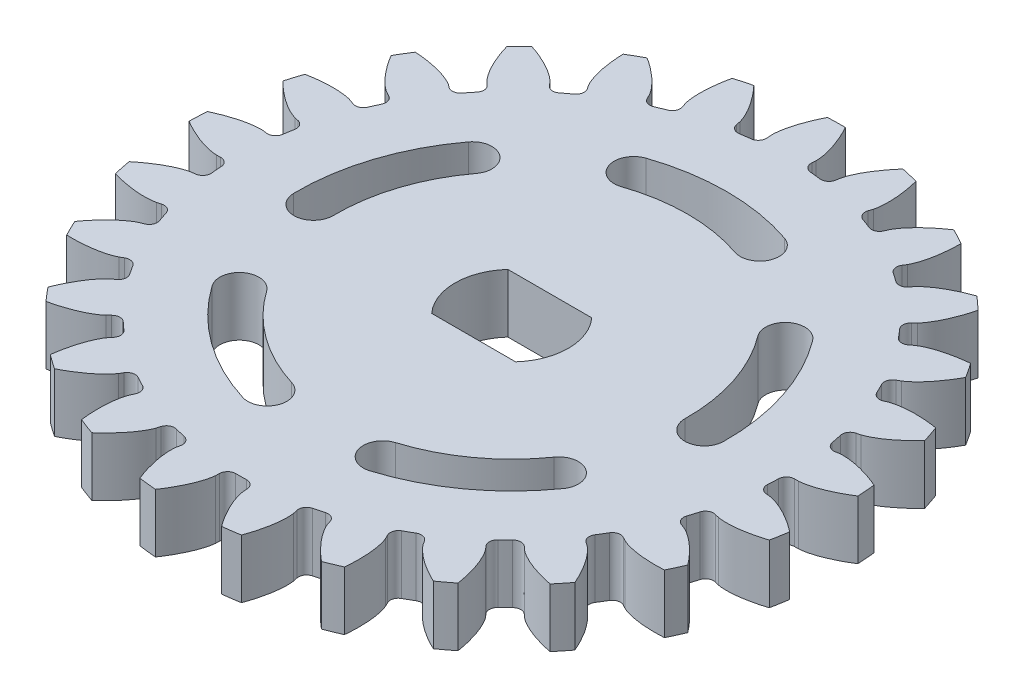
from build123d import *

# Parameters (mm, degrees)
SKETCH1_R                  = 16.875
BOSS_EXTRUDE1_DEPTH        = 3
CUT_EXTRUDE1_DEPTH         = 4
CIRPATTERN19_COUNT         = 25
CIRPATTERN19_COPY_1_DEPTH  = 4
CIRPATTERN19_COPY_2_DEPTH  = 4
CIRPATTERN19_COPY_3_DEPTH  = 4
CIRPATTERN19_COPY_4_DEPTH  = 4
CIRPATTERN19_COPY_5_DEPTH  = 4
CIRPATTERN19_COPY_6_DEPTH  = 4
CIRPATTERN19_COPY_7_DEPTH  = 4
CIRPATTERN19_COPY_8_DEPTH  = 4
CIRPATTERN19_COPY_9_DEPTH  = 4
CIRPATTERN19_COPY_10_DEPTH = 4
CIRPATTERN19_COPY_11_DEPTH = 4
CIRPATTERN19_COPY_12_DEPTH = 4
CIRPATTERN19_COPY_13_DEPTH = 4
CIRPATTERN19_COPY_14_DEPTH = 4
CIRPATTERN19_COPY_15_DEPTH = 4
CIRPATTERN19_COPY_16_DEPTH = 4
CIRPATTERN19_COPY_17_DEPTH = 4
CIRPATTERN19_COPY_18_DEPTH = 4
CIRPATTERN19_COPY_19_DEPTH = 4
CIRPATTERN19_COPY_20_DEPTH = 4
CIRPATTERN19_COPY_21_DEPTH = 4
CIRPATTERN19_COPY_22_DEPTH = 4
CIRPATTERN19_COPY_23_DEPTH = 4
CIRPATTERN19_COPY_24_DEPTH = 4
CUT_EXTRUDE2_DEPTH         = 4.0000049
CUT_EXTRUDE3_DEPTH         = 4.0000049
CIRPATTERN20_COUNT         = 5


with BuildPart() as part:
    # Sketch1 → Boss-Extrude1 (new body)
    with BuildSketch(Plane(origin=(0, 0, 0), x_dir=(1, 0, 0), z_dir=(0, 1, 0))):
        Circle(SKETCH1_R)
    extrude(amount=-BOSS_EXTRUDE1_DEPTH)

    # Sketch2 → Cut-Extrude1 (cut, through all)
    with BuildSketch(Plane(origin=(0, 0, 0), x_dir=(1, 0, 0), z_dir=(0, 1, 0))):
        with BuildLine():
            Line((14.473170221, 0), (14.6826972, 0))
            add(Edge.make_bspline(
                [(14.6826972, 0), (14.687716537, 7.2212e-05), (14.701790992, 0.000498376), (14.728380503, 0.00218708), (14.771710632, 0.006195704), (14.826812481, 0.013143385), (14.897864508, 0.024232683), (14.981306932, 0.040003826), (15.072684246, 0.060165733), (15.171694457, 0.085145599), (15.270071215, 0.112751457), (15.367794105, 0.14277984), (15.464743149, 0.174933677), (15.581665779, 0.216519036), (15.721125406, 0.270043417), (15.882938468, 0.337902676), (16.064963773, 0.421092777), (16.24872437, 0.512478794), (16.428052554, 0.607810489), (16.607375654, 0.710283683), (16.779548819, 0.813789215), (16.956297294, 0.927518774), (17.118396155, 1.035668484), (17.297531984, 1.163631233), (17.441387655, 1.268891216), (17.587819786, 1.383229542), (17.658763834, 1.439702537), (17.69488153, 1.468909522)],
                knots=[0, 0, 0, 0, 0, 0.005376749, 0.015083688, 0.02853182, 0.04661014, 0.064854849, 0.092110525, 0.119476176, 0.146842496, 0.174208854, 0.201574956, 0.228941013, 0.256307345, 0.307035032, 0.361767352, 0.416499661, 0.471231937, 0.525964282, 0.580696616, 0.635428982, 0.690161387, 0.744893688, 0.799626082, 0.854358408, 0.909090915, 0.909090915, 0.909090915, 0.909090915, 0.909090915], degree=4))
            Line((17.69488153, 1.468909522), (17.892777101, -0.858215161))
            Line((17.892777101, -0.858215161), (14.046351922, -0.673723934))
            ThreePointArc((14.046351922, -0.673723934), (14.052157943, -0.539224806), (14.056676114, -0.404676259))
            ThreePointArc((14.056676114, -0.404676259), (14.18281259, -0.117829659), (14.473170221, 0))
        make_face()
    cut_extrude1 = extrude(amount=-CUT_EXTRUDE1_DEPTH, mode=Mode.SUBTRACT)

    # Mirror2: Cut-Extrude1 across plane
    add(cut_extrude1.mirror(Plane(origin=(0, 0, 0), x_dir=(0.998851692, 0, 0.047909258), z_dir=(0.047909258, 0, -0.998851692))), mode=Mode.SUBTRACT)

    # CirPattern19: Cut-Extrude1 ×25 about axis
    cirpattern19_axis = Axis((0, 0, 0), (0, 1, 0))
    for i in range(1, CIRPATTERN19_COUNT):
        add(cut_extrude1.rotate(cirpattern19_axis, i * 360 / CIRPATTERN19_COUNT), mode=Mode.SUBTRACT)

    # CirPattern19 copy 1 sketch → CirPattern19 copy 1 (cut, through all)
    with BuildSketch(Plane(origin=(0, 0, 0), x_dir=(0.987938522, 0, -0.154846625), z_dir=(0, 1, 0))):
        with BuildLine():
            Line((14.473170221, 0), (14.6826972, 0))
            add(Edge.make_bspline(
                [(14.6826972, 0), (14.687716537, -7.2212e-05), (14.701790992, -0.000498376), (14.728380503, -0.00218708), (14.771710632, -0.006195704), (14.826812481, -0.013143385), (14.897864508, -0.024232683), (14.981306932, -0.040003826), (15.072684246, -0.060165733), (15.171694457, -0.085145599), (15.270071215, -0.112751457), (15.367794105, -0.14277984), (15.464743149, -0.174933677), (15.581665779, -0.216519036), (15.721125406, -0.270043417), (15.882938468, -0.337902676), (16.064963773, -0.421092777), (16.24872437, -0.512478794), (16.428052554, -0.607810489), (16.607375654, -0.710283683), (16.779548819, -0.813789215), (16.956297294, -0.927518774), (17.118396155, -1.035668484), (17.297531984, -1.163631233), (17.441387655, -1.268891216), (17.587819786, -1.383229542), (17.658763834, -1.439702537), (17.69488153, -1.468909522)],
                knots=[0, 0, 0, 0, 0, 0.005376749, 0.015083688, 0.02853182, 0.04661014, 0.064854849, 0.092110525, 0.119476176, 0.146842496, 0.174208854, 0.201574956, 0.228941013, 0.256307345, 0.307035032, 0.361767352, 0.416499661, 0.471231937, 0.525964282, 0.580696616, 0.635428982, 0.690161387, 0.744893688, 0.799626082, 0.854358408, 0.909090915, 0.909090915, 0.909090915, 0.909090915, 0.909090915], degree=4))
            Line((17.69488153, -1.468909522), (17.892777101, 0.858215161))
            Line((17.892777101, 0.858215161), (14.046351922, 0.673723934))
            ThreePointArc((14.046351922, 0.673723934), (14.052157943, 0.539224806), (14.056676114, 0.404676259))
            ThreePointArc((14.056676114, 0.404676259), (14.18281259, 0.117829659), (14.473170221, 0))
        make_face()
    extrude(amount=-CIRPATTERN19_COPY_1_DEPTH, mode=Mode.SUBTRACT)

    # CirPattern19 copy 2 sketch → CirPattern19 copy 2 (cut, through all)
    with BuildSketch(Plane(origin=(0, 0, 0), x_dir=(0.918391827, 0, -0.395672153), z_dir=(0, 1, 0))):
        with BuildLine():
            Line((14.473170221, 0), (14.6826972, 0))
            add(Edge.make_bspline(
                [(14.6826972, 0), (14.687716537, -7.2212e-05), (14.701790992, -0.000498376), (14.728380503, -0.00218708), (14.771710632, -0.006195704), (14.826812481, -0.013143385), (14.897864508, -0.024232683), (14.981306932, -0.040003826), (15.072684246, -0.060165733), (15.171694457, -0.085145599), (15.270071215, -0.112751457), (15.367794105, -0.14277984), (15.464743149, -0.174933677), (15.581665779, -0.216519036), (15.721125406, -0.270043417), (15.882938468, -0.337902676), (16.064963773, -0.421092777), (16.24872437, -0.512478794), (16.428052554, -0.607810489), (16.607375654, -0.710283683), (16.779548819, -0.813789215), (16.956297294, -0.927518774), (17.118396155, -1.035668484), (17.297531984, -1.163631233), (17.441387655, -1.268891216), (17.587819786, -1.383229542), (17.658763834, -1.439702537), (17.69488153, -1.468909522)],
                knots=[0, 0, 0, 0, 0, 0.005376749, 0.015083688, 0.02853182, 0.04661014, 0.064854849, 0.092110525, 0.119476176, 0.146842496, 0.174208854, 0.201574956, 0.228941013, 0.256307345, 0.307035032, 0.361767352, 0.416499661, 0.471231937, 0.525964282, 0.580696616, 0.635428982, 0.690161387, 0.744893688, 0.799626082, 0.854358408, 0.909090915, 0.909090915, 0.909090915, 0.909090915, 0.909090915], degree=4))
            Line((17.69488153, -1.468909522), (17.892777101, 0.858215161))
            Line((17.892777101, 0.858215161), (14.046351922, 0.673723934))
            ThreePointArc((14.046351922, 0.673723934), (14.052157943, 0.539224806), (14.056676114, 0.404676259))
            ThreePointArc((14.056676114, 0.404676259), (14.18281259, 0.117829659), (14.473170221, 0))
        make_face()
    extrude(amount=-CIRPATTERN19_COPY_2_DEPTH, mode=Mode.SUBTRACT)

    # CirPattern19 copy 3 sketch → CirPattern19 copy 3 (cut, through all)
    with BuildSketch(Plane(origin=(0, 0, 0), x_dir=(0.791139195, 0, -0.611636145), z_dir=(0, 1, 0))):
        with BuildLine():
            Line((14.473170221, 0), (14.6826972, 0))
            add(Edge.make_bspline(
                [(14.6826972, 0), (14.687716537, -7.2212e-05), (14.701790992, -0.000498376), (14.728380503, -0.00218708), (14.771710632, -0.006195704), (14.826812481, -0.013143385), (14.897864508, -0.024232683), (14.981306932, -0.040003826), (15.072684246, -0.060165733), (15.171694457, -0.085145599), (15.270071215, -0.112751457), (15.367794105, -0.14277984), (15.464743149, -0.174933677), (15.581665779, -0.216519036), (15.721125406, -0.270043417), (15.882938468, -0.337902676), (16.064963773, -0.421092777), (16.24872437, -0.512478794), (16.428052554, -0.607810489), (16.607375654, -0.710283683), (16.779548819, -0.813789215), (16.956297294, -0.927518774), (17.118396155, -1.035668484), (17.297531984, -1.163631233), (17.441387655, -1.268891216), (17.587819786, -1.383229542), (17.658763834, -1.439702537), (17.69488153, -1.468909522)],
                knots=[0, 0, 0, 0, 0, 0.005376749, 0.015083688, 0.02853182, 0.04661014, 0.064854849, 0.092110525, 0.119476176, 0.146842496, 0.174208854, 0.201574956, 0.228941013, 0.256307345, 0.307035032, 0.361767352, 0.416499661, 0.471231937, 0.525964282, 0.580696616, 0.635428982, 0.690161387, 0.744893688, 0.799626082, 0.854358408, 0.909090915, 0.909090915, 0.909090915, 0.909090915, 0.909090915], degree=4))
            Line((17.69488153, -1.468909522), (17.892777101, 0.858215161))
            Line((17.892777101, 0.858215161), (14.046351922, 0.673723934))
            ThreePointArc((14.046351922, 0.673723934), (14.052157943, 0.539224806), (14.056676114, 0.404676259))
            ThreePointArc((14.056676114, 0.404676259), (14.18281259, 0.117829659), (14.473170221, 0))
        make_face()
    extrude(amount=-CIRPATTERN19_COPY_3_DEPTH, mode=Mode.SUBTRACT)

    # CirPattern19 copy 4 sketch → CirPattern19 copy 4 (cut, through all)
    with BuildSketch(Plane(origin=(0, 0, 0), x_dir=(0.614176379, 0, -0.789168788), z_dir=(0, 1, 0))):
        with BuildLine():
            Line((14.473170221, 0), (14.6826972, 0))
            add(Edge.make_bspline(
                [(14.6826972, 0), (14.687716537, -7.2212e-05), (14.701790992, -0.000498376), (14.728380503, -0.00218708), (14.771710632, -0.006195704), (14.826812481, -0.013143385), (14.897864508, -0.024232683), (14.981306932, -0.040003826), (15.072684246, -0.060165733), (15.171694457, -0.085145599), (15.270071215, -0.112751457), (15.367794105, -0.14277984), (15.464743149, -0.174933677), (15.581665779, -0.216519036), (15.721125406, -0.270043417), (15.882938468, -0.337902676), (16.064963773, -0.421092777), (16.24872437, -0.512478794), (16.428052554, -0.607810489), (16.607375654, -0.710283683), (16.779548819, -0.813789215), (16.956297294, -0.927518774), (17.118396155, -1.035668484), (17.297531984, -1.163631233), (17.441387655, -1.268891216), (17.587819786, -1.383229542), (17.658763834, -1.439702537), (17.69488153, -1.468909522)],
                knots=[0, 0, 0, 0, 0, 0.005376749, 0.015083688, 0.02853182, 0.04661014, 0.064854849, 0.092110525, 0.119476176, 0.146842496, 0.174208854, 0.201574956, 0.228941013, 0.256307345, 0.307035032, 0.361767352, 0.416499661, 0.471231937, 0.525964282, 0.580696616, 0.635428982, 0.690161387, 0.744893688, 0.799626082, 0.854358408, 0.909090915, 0.909090915, 0.909090915, 0.909090915, 0.909090915], degree=4))
            Line((17.69488153, -1.468909522), (17.892777101, 0.858215161))
            Line((17.892777101, 0.858215161), (14.046351922, 0.673723934))
            ThreePointArc((14.046351922, 0.673723934), (14.052157943, 0.539224806), (14.056676114, 0.404676259))
            ThreePointArc((14.056676114, 0.404676259), (14.18281259, 0.117829659), (14.473170221, 0))
        make_face()
    extrude(amount=-CIRPATTERN19_COPY_4_DEPTH, mode=Mode.SUBTRACT)

    # CirPattern19 copy 5 sketch → CirPattern19 copy 5 (cut, through all)
    with BuildSketch(Plane(origin=(0, 0, 0), x_dir=(0.398622602, 0, -0.917115053), z_dir=(0, 1, 0))):
        with BuildLine():
            Line((14.473170221, 0), (14.6826972, 0))
            add(Edge.make_bspline(
                [(14.6826972, 0), (14.687716537, -7.2212e-05), (14.701790992, -0.000498376), (14.728380503, -0.00218708), (14.771710632, -0.006195704), (14.826812481, -0.013143385), (14.897864508, -0.024232683), (14.981306932, -0.040003826), (15.072684246, -0.060165733), (15.171694457, -0.085145599), (15.270071215, -0.112751457), (15.367794105, -0.14277984), (15.464743149, -0.174933677), (15.581665779, -0.216519036), (15.721125406, -0.270043417), (15.882938468, -0.337902676), (16.064963773, -0.421092777), (16.24872437, -0.512478794), (16.428052554, -0.607810489), (16.607375654, -0.710283683), (16.779548819, -0.813789215), (16.956297294, -0.927518774), (17.118396155, -1.035668484), (17.297531984, -1.163631233), (17.441387655, -1.268891216), (17.587819786, -1.383229542), (17.658763834, -1.439702537), (17.69488153, -1.468909522)],
                knots=[0, 0, 0, 0, 0, 0.005376749, 0.015083688, 0.02853182, 0.04661014, 0.064854849, 0.092110525, 0.119476176, 0.146842496, 0.174208854, 0.201574956, 0.228941013, 0.256307345, 0.307035032, 0.361767352, 0.416499661, 0.471231937, 0.525964282, 0.580696616, 0.635428982, 0.690161387, 0.744893688, 0.799626082, 0.854358408, 0.909090915, 0.909090915, 0.909090915, 0.909090915, 0.909090915], degree=4))
            Line((17.69488153, -1.468909522), (17.892777101, 0.858215161))
            Line((17.892777101, 0.858215161), (14.046351922, 0.673723934))
            ThreePointArc((14.046351922, 0.673723934), (14.052157943, 0.539224806), (14.056676114, 0.404676259))
            ThreePointArc((14.056676114, 0.404676259), (14.18281259, 0.117829659), (14.473170221, 0))
        make_face()
    extrude(amount=-CIRPATTERN19_COPY_5_DEPTH, mode=Mode.SUBTRACT)

    # CirPattern19 copy 6 sketch → CirPattern19 copy 6 (cut, through all)
    with BuildSketch(Plane(origin=(0, 0, 0), x_dir=(0.158021901, 0, -0.987435607), z_dir=(0, 1, 0))):
        with BuildLine():
            Line((14.473170221, 0), (14.6826972, 0))
            add(Edge.make_bspline(
                [(14.6826972, 0), (14.687716537, -7.2212e-05), (14.701790992, -0.000498376), (14.728380503, -0.00218708), (14.771710632, -0.006195704), (14.826812481, -0.013143385), (14.897864508, -0.024232683), (14.981306932, -0.040003826), (15.072684246, -0.060165733), (15.171694457, -0.085145599), (15.270071215, -0.112751457), (15.367794105, -0.14277984), (15.464743149, -0.174933677), (15.581665779, -0.216519036), (15.721125406, -0.270043417), (15.882938468, -0.337902676), (16.064963773, -0.421092777), (16.24872437, -0.512478794), (16.428052554, -0.607810489), (16.607375654, -0.710283683), (16.779548819, -0.813789215), (16.956297294, -0.927518774), (17.118396155, -1.035668484), (17.297531984, -1.163631233), (17.441387655, -1.268891216), (17.587819786, -1.383229542), (17.658763834, -1.439702537), (17.69488153, -1.468909522)],
                knots=[0, 0, 0, 0, 0, 0.005376749, 0.015083688, 0.02853182, 0.04661014, 0.064854849, 0.092110525, 0.119476176, 0.146842496, 0.174208854, 0.201574956, 0.228941013, 0.256307345, 0.307035032, 0.361767352, 0.416499661, 0.471231937, 0.525964282, 0.580696616, 0.635428982, 0.690161387, 0.744893688, 0.799626082, 0.854358408, 0.909090915, 0.909090915, 0.909090915, 0.909090915, 0.909090915], degree=4))
            Line((17.69488153, -1.468909522), (17.892777101, 0.858215161))
            Line((17.892777101, 0.858215161), (14.046351922, 0.673723934))
            ThreePointArc((14.046351922, 0.673723934), (14.052157943, 0.539224806), (14.056676114, 0.404676259))
            ThreePointArc((14.056676114, 0.404676259), (14.18281259, 0.117829659), (14.473170221, 0))
        make_face()
    extrude(amount=-CIRPATTERN19_COPY_6_DEPTH, mode=Mode.SUBTRACT)

    # CirPattern19 copy 7 sketch → CirPattern19 copy 7 (cut, through all)
    with BuildSketch(Plane(origin=(0, 0, 0), x_dir=(-0.092507898, 0, -0.995711951), z_dir=(0, 1, 0))):
        with BuildLine():
            Line((14.473170221, 0), (14.6826972, 0))
            add(Edge.make_bspline(
                [(14.6826972, 0), (14.687716537, -7.2212e-05), (14.701790992, -0.000498376), (14.728380503, -0.00218708), (14.771710632, -0.006195704), (14.826812481, -0.013143385), (14.897864508, -0.024232683), (14.981306932, -0.040003826), (15.072684246, -0.060165733), (15.171694457, -0.085145599), (15.270071215, -0.112751457), (15.367794105, -0.14277984), (15.464743149, -0.174933677), (15.581665779, -0.216519036), (15.721125406, -0.270043417), (15.882938468, -0.337902676), (16.064963773, -0.421092777), (16.24872437, -0.512478794), (16.428052554, -0.607810489), (16.607375654, -0.710283683), (16.779548819, -0.813789215), (16.956297294, -0.927518774), (17.118396155, -1.035668484), (17.297531984, -1.163631233), (17.441387655, -1.268891216), (17.587819786, -1.383229542), (17.658763834, -1.439702537), (17.69488153, -1.468909522)],
                knots=[0, 0, 0, 0, 0, 0.005376749, 0.015083688, 0.02853182, 0.04661014, 0.064854849, 0.092110525, 0.119476176, 0.146842496, 0.174208854, 0.201574956, 0.228941013, 0.256307345, 0.307035032, 0.361767352, 0.416499661, 0.471231937, 0.525964282, 0.580696616, 0.635428982, 0.690161387, 0.744893688, 0.799626082, 0.854358408, 0.909090915, 0.909090915, 0.909090915, 0.909090915, 0.909090915], degree=4))
            Line((17.69488153, -1.468909522), (17.892777101, 0.858215161))
            Line((17.892777101, 0.858215161), (14.046351922, 0.673723934))
            ThreePointArc((14.046351922, 0.673723934), (14.052157943, 0.539224806), (14.056676114, 0.404676259))
            ThreePointArc((14.056676114, 0.404676259), (14.18281259, 0.117829659), (14.473170221, 0))
        make_face()
    extrude(amount=-CIRPATTERN19_COPY_7_DEPTH, mode=Mode.SUBTRACT)

    # CirPattern19 copy 8 sketch → CirPattern19 copy 8 (cut, through all)
    with BuildSketch(Plane(origin=(0, 0, 0), x_dir=(-0.337225085, 0, -0.94142405), z_dir=(0, 1, 0))):
        with BuildLine():
            Line((14.473170221, 0), (14.6826972, 0))
            add(Edge.make_bspline(
                [(14.6826972, 0), (14.687716537, -7.2212e-05), (14.701790992, -0.000498376), (14.728380503, -0.00218708), (14.771710632, -0.006195704), (14.826812481, -0.013143385), (14.897864508, -0.024232683), (14.981306932, -0.040003826), (15.072684246, -0.060165733), (15.171694457, -0.085145599), (15.270071215, -0.112751457), (15.367794105, -0.14277984), (15.464743149, -0.174933677), (15.581665779, -0.216519036), (15.721125406, -0.270043417), (15.882938468, -0.337902676), (16.064963773, -0.421092777), (16.24872437, -0.512478794), (16.428052554, -0.607810489), (16.607375654, -0.710283683), (16.779548819, -0.813789215), (16.956297294, -0.927518774), (17.118396155, -1.035668484), (17.297531984, -1.163631233), (17.441387655, -1.268891216), (17.587819786, -1.383229542), (17.658763834, -1.439702537), (17.69488153, -1.468909522)],
                knots=[0, 0, 0, 0, 0, 0.005376749, 0.015083688, 0.02853182, 0.04661014, 0.064854849, 0.092110525, 0.119476176, 0.146842496, 0.174208854, 0.201574956, 0.228941013, 0.256307345, 0.307035032, 0.361767352, 0.416499661, 0.471231937, 0.525964282, 0.580696616, 0.635428982, 0.690161387, 0.744893688, 0.799626082, 0.854358408, 0.909090915, 0.909090915, 0.909090915, 0.909090915, 0.909090915], degree=4))
            Line((17.69488153, -1.468909522), (17.892777101, 0.858215161))
            Line((17.892777101, 0.858215161), (14.046351922, 0.673723934))
            ThreePointArc((14.046351922, 0.673723934), (14.052157943, 0.539224806), (14.056676114, 0.404676259))
            ThreePointArc((14.056676114, 0.404676259), (14.18281259, 0.117829659), (14.473170221, 0))
        make_face()
    extrude(amount=-CIRPATTERN19_COPY_8_DEPTH, mode=Mode.SUBTRACT)

    # CirPattern19 copy 9 sketch → CirPattern19 copy 9 (cut, through all)
    with BuildSketch(Plane(origin=(0, 0, 0), x_dir=(-0.560753179, 0, -0.827983014), z_dir=(0, 1, 0))):
        with BuildLine():
            Line((14.473170221, 0), (14.6826972, 0))
            add(Edge.make_bspline(
                [(14.6826972, 0), (14.687716537, -7.2212e-05), (14.701790992, -0.000498376), (14.728380503, -0.00218708), (14.771710632, -0.006195704), (14.826812481, -0.013143385), (14.897864508, -0.024232683), (14.981306932, -0.040003826), (15.072684246, -0.060165733), (15.171694457, -0.085145599), (15.270071215, -0.112751457), (15.367794105, -0.14277984), (15.464743149, -0.174933677), (15.581665779, -0.216519036), (15.721125406, -0.270043417), (15.882938468, -0.337902676), (16.064963773, -0.421092777), (16.24872437, -0.512478794), (16.428052554, -0.607810489), (16.607375654, -0.710283683), (16.779548819, -0.813789215), (16.956297294, -0.927518774), (17.118396155, -1.035668484), (17.297531984, -1.163631233), (17.441387655, -1.268891216), (17.587819786, -1.383229542), (17.658763834, -1.439702537), (17.69488153, -1.468909522)],
                knots=[0, 0, 0, 0, 0, 0.005376749, 0.015083688, 0.02853182, 0.04661014, 0.064854849, 0.092110525, 0.119476176, 0.146842496, 0.174208854, 0.201574956, 0.228941013, 0.256307345, 0.307035032, 0.361767352, 0.416499661, 0.471231937, 0.525964282, 0.580696616, 0.635428982, 0.690161387, 0.744893688, 0.799626082, 0.854358408, 0.909090915, 0.909090915, 0.909090915, 0.909090915, 0.909090915], degree=4))
            Line((17.69488153, -1.468909522), (17.892777101, 0.858215161))
            Line((17.892777101, 0.858215161), (14.046351922, 0.673723934))
            ThreePointArc((14.046351922, 0.673723934), (14.052157943, 0.539224806), (14.056676114, 0.404676259))
            ThreePointArc((14.056676114, 0.404676259), (14.18281259, 0.117829659), (14.473170221, 0))
        make_face()
    extrude(amount=-CIRPATTERN19_COPY_9_DEPTH, mode=Mode.SUBTRACT)

    # CirPattern19 copy 10 sketch → CirPattern19 copy 10 (cut, through all)
    with BuildSketch(Plane(origin=(0, 0, 0), x_dir=(-0.749047089, 0, -0.66251676), z_dir=(0, 1, 0))):
        with BuildLine():
            Line((14.473170221, 0), (14.6826972, 0))
            add(Edge.make_bspline(
                [(14.6826972, 0), (14.687716537, -7.2212e-05), (14.701790992, -0.000498376), (14.728380503, -0.00218708), (14.771710632, -0.006195704), (14.826812481, -0.013143385), (14.897864508, -0.024232683), (14.981306932, -0.040003826), (15.072684246, -0.060165733), (15.171694457, -0.085145599), (15.270071215, -0.112751457), (15.367794105, -0.14277984), (15.464743149, -0.174933677), (15.581665779, -0.216519036), (15.721125406, -0.270043417), (15.882938468, -0.337902676), (16.064963773, -0.421092777), (16.24872437, -0.512478794), (16.428052554, -0.607810489), (16.607375654, -0.710283683), (16.779548819, -0.813789215), (16.956297294, -0.927518774), (17.118396155, -1.035668484), (17.297531984, -1.163631233), (17.441387655, -1.268891216), (17.587819786, -1.383229542), (17.658763834, -1.439702537), (17.69488153, -1.468909522)],
                knots=[0, 0, 0, 0, 0, 0.005376749, 0.015083688, 0.02853182, 0.04661014, 0.064854849, 0.092110525, 0.119476176, 0.146842496, 0.174208854, 0.201574956, 0.228941013, 0.256307345, 0.307035032, 0.361767352, 0.416499661, 0.471231937, 0.525964282, 0.580696616, 0.635428982, 0.690161387, 0.744893688, 0.799626082, 0.854358408, 0.909090915, 0.909090915, 0.909090915, 0.909090915, 0.909090915], degree=4))
            Line((17.69488153, -1.468909522), (17.892777101, 0.858215161))
            Line((17.892777101, 0.858215161), (14.046351922, 0.673723934))
            ThreePointArc((14.046351922, 0.673723934), (14.052157943, 0.539224806), (14.056676114, 0.404676259))
            ThreePointArc((14.056676114, 0.404676259), (14.18281259, 0.117829659), (14.473170221, 0))
        make_face()
    extrude(amount=-CIRPATTERN19_COPY_10_DEPTH, mode=Mode.SUBTRACT)

    # CirPattern19 copy 11 sketch → CirPattern19 copy 11 (cut, through all)
    with BuildSketch(Plane(origin=(0, 0, 0), x_dir=(-0.890275616, 0, -0.455422142), z_dir=(0, 1, 0))):
        with BuildLine():
            Line((14.473170221, 0), (14.6826972, 0))
            add(Edge.make_bspline(
                [(14.6826972, 0), (14.687716537, -7.2212e-05), (14.701790992, -0.000498376), (14.728380503, -0.00218708), (14.771710632, -0.006195704), (14.826812481, -0.013143385), (14.897864508, -0.024232683), (14.981306932, -0.040003826), (15.072684246, -0.060165733), (15.171694457, -0.085145599), (15.270071215, -0.112751457), (15.367794105, -0.14277984), (15.464743149, -0.174933677), (15.581665779, -0.216519036), (15.721125406, -0.270043417), (15.882938468, -0.337902676), (16.064963773, -0.421092777), (16.24872437, -0.512478794), (16.428052554, -0.607810489), (16.607375654, -0.710283683), (16.779548819, -0.813789215), (16.956297294, -0.927518774), (17.118396155, -1.035668484), (17.297531984, -1.163631233), (17.441387655, -1.268891216), (17.587819786, -1.383229542), (17.658763834, -1.439702537), (17.69488153, -1.468909522)],
                knots=[0, 0, 0, 0, 0, 0.005376749, 0.015083688, 0.02853182, 0.04661014, 0.064854849, 0.092110525, 0.119476176, 0.146842496, 0.174208854, 0.201574956, 0.228941013, 0.256307345, 0.307035032, 0.361767352, 0.416499661, 0.471231937, 0.525964282, 0.580696616, 0.635428982, 0.690161387, 0.744893688, 0.799626082, 0.854358408, 0.909090915, 0.909090915, 0.909090915, 0.909090915, 0.909090915], degree=4))
            Line((17.69488153, -1.468909522), (17.892777101, 0.858215161))
            Line((17.892777101, 0.858215161), (14.046351922, 0.673723934))
            ThreePointArc((14.046351922, 0.673723934), (14.052157943, 0.539224806), (14.056676114, 0.404676259))
            ThreePointArc((14.056676114, 0.404676259), (14.18281259, 0.117829659), (14.473170221, 0))
        make_face()
    extrude(amount=-CIRPATTERN19_COPY_11_DEPTH, mode=Mode.SUBTRACT)

    # CirPattern19 copy 12 sketch → CirPattern19 copy 12 (cut, through all)
    with BuildSketch(Plane(origin=(0, 0, 0), x_dir=(-0.975564852, 0, -0.219711675), z_dir=(0, 1, 0))):
        with BuildLine():
            Line((14.473170221, 0), (14.6826972, 0))
            add(Edge.make_bspline(
                [(14.6826972, 0), (14.687716537, -7.2212e-05), (14.701790992, -0.000498376), (14.728380503, -0.00218708), (14.771710632, -0.006195704), (14.826812481, -0.013143385), (14.897864508, -0.024232683), (14.981306932, -0.040003826), (15.072684246, -0.060165733), (15.171694457, -0.085145599), (15.270071215, -0.112751457), (15.367794105, -0.14277984), (15.464743149, -0.174933677), (15.581665779, -0.216519036), (15.721125406, -0.270043417), (15.882938468, -0.337902676), (16.064963773, -0.421092777), (16.24872437, -0.512478794), (16.428052554, -0.607810489), (16.607375654, -0.710283683), (16.779548819, -0.813789215), (16.956297294, -0.927518774), (17.118396155, -1.035668484), (17.297531984, -1.163631233), (17.441387655, -1.268891216), (17.587819786, -1.383229542), (17.658763834, -1.439702537), (17.69488153, -1.468909522)],
                knots=[0, 0, 0, 0, 0, 0.005376749, 0.015083688, 0.02853182, 0.04661014, 0.064854849, 0.092110525, 0.119476176, 0.146842496, 0.174208854, 0.201574956, 0.228941013, 0.256307345, 0.307035032, 0.361767352, 0.416499661, 0.471231937, 0.525964282, 0.580696616, 0.635428982, 0.690161387, 0.744893688, 0.799626082, 0.854358408, 0.909090915, 0.909090915, 0.909090915, 0.909090915, 0.909090915], degree=4))
            Line((17.69488153, -1.468909522), (17.892777101, 0.858215161))
            Line((17.892777101, 0.858215161), (14.046351922, 0.673723934))
            ThreePointArc((14.046351922, 0.673723934), (14.052157943, 0.539224806), (14.056676114, 0.404676259))
            ThreePointArc((14.056676114, 0.404676259), (14.18281259, 0.117829659), (14.473170221, 0))
        make_face()
    extrude(amount=-CIRPATTERN19_COPY_12_DEPTH, mode=Mode.SUBTRACT)

    # CirPattern19 copy 13 sketch → CirPattern19 copy 13 (cut, through all)
    with BuildSketch(Plane(origin=(0, 0, 0), x_dir=(-0.99955576, 0, 0.029804084), z_dir=(0, 1, 0))):
        with BuildLine():
            Line((14.473170221, 0), (14.6826972, 0))
            add(Edge.make_bspline(
                [(14.6826972, 0), (14.687716537, -7.2212e-05), (14.701790992, -0.000498376), (14.728380503, -0.00218708), (14.771710632, -0.006195704), (14.826812481, -0.013143385), (14.897864508, -0.024232683), (14.981306932, -0.040003826), (15.072684246, -0.060165733), (15.171694457, -0.085145599), (15.270071215, -0.112751457), (15.367794105, -0.14277984), (15.464743149, -0.174933677), (15.581665779, -0.216519036), (15.721125406, -0.270043417), (15.882938468, -0.337902676), (16.064963773, -0.421092777), (16.24872437, -0.512478794), (16.428052554, -0.607810489), (16.607375654, -0.710283683), (16.779548819, -0.813789215), (16.956297294, -0.927518774), (17.118396155, -1.035668484), (17.297531984, -1.163631233), (17.441387655, -1.268891216), (17.587819786, -1.383229542), (17.658763834, -1.439702537), (17.69488153, -1.468909522)],
                knots=[0, 0, 0, 0, 0, 0.005376749, 0.015083688, 0.02853182, 0.04661014, 0.064854849, 0.092110525, 0.119476176, 0.146842496, 0.174208854, 0.201574956, 0.228941013, 0.256307345, 0.307035032, 0.361767352, 0.416499661, 0.471231937, 0.525964282, 0.580696616, 0.635428982, 0.690161387, 0.744893688, 0.799626082, 0.854358408, 0.909090915, 0.909090915, 0.909090915, 0.909090915, 0.909090915], degree=4))
            Line((17.69488153, -1.468909522), (17.892777101, 0.858215161))
            Line((17.892777101, 0.858215161), (14.046351922, 0.673723934))
            ThreePointArc((14.046351922, 0.673723934), (14.052157943, 0.539224806), (14.056676114, 0.404676259))
            ThreePointArc((14.056676114, 0.404676259), (14.18281259, 0.117829659), (14.473170221, 0))
        make_face()
    extrude(amount=-CIRPATTERN19_COPY_13_DEPTH, mode=Mode.SUBTRACT)

    # CirPattern19 copy 14 sketch → CirPattern19 copy 14 (cut, through all)
    with BuildSketch(Plane(origin=(0, 0, 0), x_dir=(-0.960740903, 0, 0.277447143), z_dir=(0, 1, 0))):
        with BuildLine():
            Line((14.473170221, 0), (14.6826972, 0))
            add(Edge.make_bspline(
                [(14.6826972, 0), (14.687716537, -7.2212e-05), (14.701790992, -0.000498376), (14.728380503, -0.00218708), (14.771710632, -0.006195704), (14.826812481, -0.013143385), (14.897864508, -0.024232683), (14.981306932, -0.040003826), (15.072684246, -0.060165733), (15.171694457, -0.085145599), (15.270071215, -0.112751457), (15.367794105, -0.14277984), (15.464743149, -0.174933677), (15.581665779, -0.216519036), (15.721125406, -0.270043417), (15.882938468, -0.337902676), (16.064963773, -0.421092777), (16.24872437, -0.512478794), (16.428052554, -0.607810489), (16.607375654, -0.710283683), (16.779548819, -0.813789215), (16.956297294, -0.927518774), (17.118396155, -1.035668484), (17.297531984, -1.163631233), (17.441387655, -1.268891216), (17.587819786, -1.383229542), (17.658763834, -1.439702537), (17.69488153, -1.468909522)],
                knots=[0, 0, 0, 0, 0, 0.005376749, 0.015083688, 0.02853182, 0.04661014, 0.064854849, 0.092110525, 0.119476176, 0.146842496, 0.174208854, 0.201574956, 0.228941013, 0.256307345, 0.307035032, 0.361767352, 0.416499661, 0.471231937, 0.525964282, 0.580696616, 0.635428982, 0.690161387, 0.744893688, 0.799626082, 0.854358408, 0.909090915, 0.909090915, 0.909090915, 0.909090915, 0.909090915], degree=4))
            Line((17.69488153, -1.468909522), (17.892777101, 0.858215161))
            Line((17.892777101, 0.858215161), (14.046351922, 0.673723934))
            ThreePointArc((14.046351922, 0.673723934), (14.052157943, 0.539224806), (14.056676114, 0.404676259))
            ThreePointArc((14.056676114, 0.404676259), (14.18281259, 0.117829659), (14.473170221, 0))
        make_face()
    extrude(amount=-CIRPATTERN19_COPY_14_DEPTH, mode=Mode.SUBTRACT)

    # CirPattern19 copy 15 sketch → CirPattern19 copy 15 (cut, through all)
    with BuildSketch(Plane(origin=(0, 0, 0), x_dir=(-0.861559162, 0, 0.507657177), z_dir=(0, 1, 0))):
        with BuildLine():
            Line((14.473170221, 0), (14.6826972, 0))
            add(Edge.make_bspline(
                [(14.6826972, 0), (14.687716537, -7.2212e-05), (14.701790992, -0.000498376), (14.728380503, -0.00218708), (14.771710632, -0.006195704), (14.826812481, -0.013143385), (14.897864508, -0.024232683), (14.981306932, -0.040003826), (15.072684246, -0.060165733), (15.171694457, -0.085145599), (15.270071215, -0.112751457), (15.367794105, -0.14277984), (15.464743149, -0.174933677), (15.581665779, -0.216519036), (15.721125406, -0.270043417), (15.882938468, -0.337902676), (16.064963773, -0.421092777), (16.24872437, -0.512478794), (16.428052554, -0.607810489), (16.607375654, -0.710283683), (16.779548819, -0.813789215), (16.956297294, -0.927518774), (17.118396155, -1.035668484), (17.297531984, -1.163631233), (17.441387655, -1.268891216), (17.587819786, -1.383229542), (17.658763834, -1.439702537), (17.69488153, -1.468909522)],
                knots=[0, 0, 0, 0, 0, 0.005376749, 0.015083688, 0.02853182, 0.04661014, 0.064854849, 0.092110525, 0.119476176, 0.146842496, 0.174208854, 0.201574956, 0.228941013, 0.256307345, 0.307035032, 0.361767352, 0.416499661, 0.471231937, 0.525964282, 0.580696616, 0.635428982, 0.690161387, 0.744893688, 0.799626082, 0.854358408, 0.909090915, 0.909090915, 0.909090915, 0.909090915, 0.909090915], degree=4))
            Line((17.69488153, -1.468909522), (17.892777101, 0.858215161))
            Line((17.892777101, 0.858215161), (14.046351922, 0.673723934))
            ThreePointArc((14.046351922, 0.673723934), (14.052157943, 0.539224806), (14.056676114, 0.404676259))
            ThreePointArc((14.056676114, 0.404676259), (14.18281259, 0.117829659), (14.473170221, 0))
        make_face()
    extrude(amount=-CIRPATTERN19_COPY_15_DEPTH, mode=Mode.SUBTRACT)

    # CirPattern19 copy 16 sketch → CirPattern19 copy 16 (cut, through all)
    with BuildSketch(Plane(origin=(0, 0, 0), x_dir=(-0.708242491, 0, 0.705969244), z_dir=(0, 1, 0))):
        with BuildLine():
            Line((14.473170221, 0), (14.6826972, 0))
            add(Edge.make_bspline(
                [(14.6826972, 0), (14.687716537, -7.2212e-05), (14.701790992, -0.000498376), (14.728380503, -0.00218708), (14.771710632, -0.006195704), (14.826812481, -0.013143385), (14.897864508, -0.024232683), (14.981306932, -0.040003826), (15.072684246, -0.060165733), (15.171694457, -0.085145599), (15.270071215, -0.112751457), (15.367794105, -0.14277984), (15.464743149, -0.174933677), (15.581665779, -0.216519036), (15.721125406, -0.270043417), (15.882938468, -0.337902676), (16.064963773, -0.421092777), (16.24872437, -0.512478794), (16.428052554, -0.607810489), (16.607375654, -0.710283683), (16.779548819, -0.813789215), (16.956297294, -0.927518774), (17.118396155, -1.035668484), (17.297531984, -1.163631233), (17.441387655, -1.268891216), (17.587819786, -1.383229542), (17.658763834, -1.439702537), (17.69488153, -1.468909522)],
                knots=[0, 0, 0, 0, 0, 0.005376749, 0.015083688, 0.02853182, 0.04661014, 0.064854849, 0.092110525, 0.119476176, 0.146842496, 0.174208854, 0.201574956, 0.228941013, 0.256307345, 0.307035032, 0.361767352, 0.416499661, 0.471231937, 0.525964282, 0.580696616, 0.635428982, 0.690161387, 0.744893688, 0.799626082, 0.854358408, 0.909090915, 0.909090915, 0.909090915, 0.909090915, 0.909090915], degree=4))
            Line((17.69488153, -1.468909522), (17.892777101, 0.858215161))
            Line((17.892777101, 0.858215161), (14.046351922, 0.673723934))
            ThreePointArc((14.046351922, 0.673723934), (14.052157943, 0.539224806), (14.056676114, 0.404676259))
            ThreePointArc((14.056676114, 0.404676259), (14.18281259, 0.117829659), (14.473170221, 0))
        make_face()
    extrude(amount=-CIRPATTERN19_COPY_16_DEPTH, mode=Mode.SUBTRACT)

    # CirPattern19 copy 17 sketch → CirPattern19 copy 17 (cut, through all)
    with BuildSketch(Plane(origin=(0, 0, 0), x_dir=(-0.510424339, 0, 0.859922668), z_dir=(0, 1, 0))):
        with BuildLine():
            Line((14.473170221, 0), (14.6826972, 0))
            add(Edge.make_bspline(
                [(14.6826972, 0), (14.687716537, -7.2212e-05), (14.701790992, -0.000498376), (14.728380503, -0.00218708), (14.771710632, -0.006195704), (14.826812481, -0.013143385), (14.897864508, -0.024232683), (14.981306932, -0.040003826), (15.072684246, -0.060165733), (15.171694457, -0.085145599), (15.270071215, -0.112751457), (15.367794105, -0.14277984), (15.464743149, -0.174933677), (15.581665779, -0.216519036), (15.721125406, -0.270043417), (15.882938468, -0.337902676), (16.064963773, -0.421092777), (16.24872437, -0.512478794), (16.428052554, -0.607810489), (16.607375654, -0.710283683), (16.779548819, -0.813789215), (16.956297294, -0.927518774), (17.118396155, -1.035668484), (17.297531984, -1.163631233), (17.441387655, -1.268891216), (17.587819786, -1.383229542), (17.658763834, -1.439702537), (17.69488153, -1.468909522)],
                knots=[0, 0, 0, 0, 0, 0.005376749, 0.015083688, 0.02853182, 0.04661014, 0.064854849, 0.092110525, 0.119476176, 0.146842496, 0.174208854, 0.201574956, 0.228941013, 0.256307345, 0.307035032, 0.361767352, 0.416499661, 0.471231937, 0.525964282, 0.580696616, 0.635428982, 0.690161387, 0.744893688, 0.799626082, 0.854358408, 0.909090915, 0.909090915, 0.909090915, 0.909090915, 0.909090915], degree=4))
            Line((17.69488153, -1.468909522), (17.892777101, 0.858215161))
            Line((17.892777101, 0.858215161), (14.046351922, 0.673723934))
            ThreePointArc((14.046351922, 0.673723934), (14.052157943, 0.539224806), (14.056676114, 0.404676259))
            ThreePointArc((14.056676114, 0.404676259), (14.18281259, 0.117829659), (14.473170221, 0))
        make_face()
    extrude(amount=-CIRPATTERN19_COPY_17_DEPTH, mode=Mode.SUBTRACT)

    # CirPattern19 copy 18 sketch → CirPattern19 copy 18 (cut, through all)
    with BuildSketch(Plane(origin=(0, 0, 0), x_dir=(-0.280534349, 0, 0.959843987), z_dir=(0, 1, 0))):
        with BuildLine():
            Line((14.473170221, 0), (14.6826972, 0))
            add(Edge.make_bspline(
                [(14.6826972, 0), (14.687716537, -7.2212e-05), (14.701790992, -0.000498376), (14.728380503, -0.00218708), (14.771710632, -0.006195704), (14.826812481, -0.013143385), (14.897864508, -0.024232683), (14.981306932, -0.040003826), (15.072684246, -0.060165733), (15.171694457, -0.085145599), (15.270071215, -0.112751457), (15.367794105, -0.14277984), (15.464743149, -0.174933677), (15.581665779, -0.216519036), (15.721125406, -0.270043417), (15.882938468, -0.337902676), (16.064963773, -0.421092777), (16.24872437, -0.512478794), (16.428052554, -0.607810489), (16.607375654, -0.710283683), (16.779548819, -0.813789215), (16.956297294, -0.927518774), (17.118396155, -1.035668484), (17.297531984, -1.163631233), (17.441387655, -1.268891216), (17.587819786, -1.383229542), (17.658763834, -1.439702537), (17.69488153, -1.468909522)],
                knots=[0, 0, 0, 0, 0, 0.005376749, 0.015083688, 0.02853182, 0.04661014, 0.064854849, 0.092110525, 0.119476176, 0.146842496, 0.174208854, 0.201574956, 0.228941013, 0.256307345, 0.307035032, 0.361767352, 0.416499661, 0.471231937, 0.525964282, 0.580696616, 0.635428982, 0.690161387, 0.744893688, 0.799626082, 0.854358408, 0.909090915, 0.909090915, 0.909090915, 0.909090915, 0.909090915], degree=4))
            Line((17.69488153, -1.468909522), (17.892777101, 0.858215161))
            Line((17.892777101, 0.858215161), (14.046351922, 0.673723934))
            ThreePointArc((14.046351922, 0.673723934), (14.052157943, 0.539224806), (14.056676114, 0.404676259))
            ThreePointArc((14.056676114, 0.404676259), (14.18281259, 0.117829659), (14.473170221, 0))
        make_face()
    extrude(amount=-CIRPATTERN19_COPY_18_DEPTH, mode=Mode.SUBTRACT)

    # CirPattern19 copy 19 sketch → CirPattern19 copy 19 (cut, through all)
    with BuildSketch(Plane(origin=(0, 0, 0), x_dir=(-0.033017353, 0, 0.999454779), z_dir=(0, 1, 0))):
        with BuildLine():
            Line((14.473170221, 0), (14.6826972, 0))
            add(Edge.make_bspline(
                [(14.6826972, 0), (14.687716537, -7.2212e-05), (14.701790992, -0.000498376), (14.728380503, -0.00218708), (14.771710632, -0.006195704), (14.826812481, -0.013143385), (14.897864508, -0.024232683), (14.981306932, -0.040003826), (15.072684246, -0.060165733), (15.171694457, -0.085145599), (15.270071215, -0.112751457), (15.367794105, -0.14277984), (15.464743149, -0.174933677), (15.581665779, -0.216519036), (15.721125406, -0.270043417), (15.882938468, -0.337902676), (16.064963773, -0.421092777), (16.24872437, -0.512478794), (16.428052554, -0.607810489), (16.607375654, -0.710283683), (16.779548819, -0.813789215), (16.956297294, -0.927518774), (17.118396155, -1.035668484), (17.297531984, -1.163631233), (17.441387655, -1.268891216), (17.587819786, -1.383229542), (17.658763834, -1.439702537), (17.69488153, -1.468909522)],
                knots=[0, 0, 0, 0, 0, 0.005376749, 0.015083688, 0.02853182, 0.04661014, 0.064854849, 0.092110525, 0.119476176, 0.146842496, 0.174208854, 0.201574956, 0.228941013, 0.256307345, 0.307035032, 0.361767352, 0.416499661, 0.471231937, 0.525964282, 0.580696616, 0.635428982, 0.690161387, 0.744893688, 0.799626082, 0.854358408, 0.909090915, 0.909090915, 0.909090915, 0.909090915, 0.909090915], degree=4))
            Line((17.69488153, -1.468909522), (17.892777101, 0.858215161))
            Line((17.892777101, 0.858215161), (14.046351922, 0.673723934))
            ThreePointArc((14.046351922, 0.673723934), (14.052157943, 0.539224806), (14.056676114, 0.404676259))
            ThreePointArc((14.056676114, 0.404676259), (14.18281259, 0.117829659), (14.473170221, 0))
        make_face()
    extrude(amount=-CIRPATTERN19_COPY_19_DEPTH, mode=Mode.SUBTRACT)

    # CirPattern19 copy 20 sketch → CirPattern19 copy 20 (cut, through all)
    with BuildSketch(Plane(origin=(0, 0, 0), x_dir=(0.216574244, 0, 0.976266151), z_dir=(0, 1, 0))):
        with BuildLine():
            Line((14.473170221, 0), (14.6826972, 0))
            add(Edge.make_bspline(
                [(14.6826972, 0), (14.687716537, -7.2212e-05), (14.701790992, -0.000498376), (14.728380503, -0.00218708), (14.771710632, -0.006195704), (14.826812481, -0.013143385), (14.897864508, -0.024232683), (14.981306932, -0.040003826), (15.072684246, -0.060165733), (15.171694457, -0.085145599), (15.270071215, -0.112751457), (15.367794105, -0.14277984), (15.464743149, -0.174933677), (15.581665779, -0.216519036), (15.721125406, -0.270043417), (15.882938468, -0.337902676), (16.064963773, -0.421092777), (16.24872437, -0.512478794), (16.428052554, -0.607810489), (16.607375654, -0.710283683), (16.779548819, -0.813789215), (16.956297294, -0.927518774), (17.118396155, -1.035668484), (17.297531984, -1.163631233), (17.441387655, -1.268891216), (17.587819786, -1.383229542), (17.658763834, -1.439702537), (17.69488153, -1.468909522)],
                knots=[0, 0, 0, 0, 0, 0.005376749, 0.015083688, 0.02853182, 0.04661014, 0.064854849, 0.092110525, 0.119476176, 0.146842496, 0.174208854, 0.201574956, 0.228941013, 0.256307345, 0.307035032, 0.361767352, 0.416499661, 0.471231937, 0.525964282, 0.580696616, 0.635428982, 0.690161387, 0.744893688, 0.799626082, 0.854358408, 0.909090915, 0.909090915, 0.909090915, 0.909090915, 0.909090915], degree=4))
            Line((17.69488153, -1.468909522), (17.892777101, 0.858215161))
            Line((17.892777101, 0.858215161), (14.046351922, 0.673723934))
            ThreePointArc((14.046351922, 0.673723934), (14.052157943, 0.539224806), (14.056676114, 0.404676259))
            ThreePointArc((14.056676114, 0.404676259), (14.18281259, 0.117829659), (14.473170221, 0))
        make_face()
    extrude(amount=-CIRPATTERN19_COPY_20_DEPTH, mode=Mode.SUBTRACT)

    # CirPattern19 copy 21 sketch → CirPattern19 copy 21 (cut, through all)
    with BuildSketch(Plane(origin=(0, 0, 0), x_dir=(0.452557684, 0, 0.89173513), z_dir=(0, 1, 0))):
        with BuildLine():
            Line((14.473170221, 0), (14.6826972, 0))
            add(Edge.make_bspline(
                [(14.6826972, 0), (14.687716537, -7.2212e-05), (14.701790992, -0.000498376), (14.728380503, -0.00218708), (14.771710632, -0.006195704), (14.826812481, -0.013143385), (14.897864508, -0.024232683), (14.981306932, -0.040003826), (15.072684246, -0.060165733), (15.171694457, -0.085145599), (15.270071215, -0.112751457), (15.367794105, -0.14277984), (15.464743149, -0.174933677), (15.581665779, -0.216519036), (15.721125406, -0.270043417), (15.882938468, -0.337902676), (16.064963773, -0.421092777), (16.24872437, -0.512478794), (16.428052554, -0.607810489), (16.607375654, -0.710283683), (16.779548819, -0.813789215), (16.956297294, -0.927518774), (17.118396155, -1.035668484), (17.297531984, -1.163631233), (17.441387655, -1.268891216), (17.587819786, -1.383229542), (17.658763834, -1.439702537), (17.69488153, -1.468909522)],
                knots=[0, 0, 0, 0, 0, 0.005376749, 0.015083688, 0.02853182, 0.04661014, 0.064854849, 0.092110525, 0.119476176, 0.146842496, 0.174208854, 0.201574956, 0.228941013, 0.256307345, 0.307035032, 0.361767352, 0.416499661, 0.471231937, 0.525964282, 0.580696616, 0.635428982, 0.690161387, 0.744893688, 0.799626082, 0.854358408, 0.909090915, 0.909090915, 0.909090915, 0.909090915, 0.909090915], degree=4))
            Line((17.69488153, -1.468909522), (17.892777101, 0.858215161))
            Line((17.892777101, 0.858215161), (14.046351922, 0.673723934))
            ThreePointArc((14.046351922, 0.673723934), (14.052157943, 0.539224806), (14.056676114, 0.404676259))
            ThreePointArc((14.056676114, 0.404676259), (14.18281259, 0.117829659), (14.473170221, 0))
        make_face()
    extrude(amount=-CIRPATTERN19_COPY_21_DEPTH, mode=Mode.SUBTRACT)

    # CirPattern19 copy 22 sketch → CirPattern19 copy 22 (cut, through all)
    with BuildSketch(Plane(origin=(0, 0, 0), x_dir=(0.660105261, 0, 0.751173112), z_dir=(0, 1, 0))):
        with BuildLine():
            Line((14.473170221, 0), (14.6826972, 0))
            add(Edge.make_bspline(
                [(14.6826972, 0), (14.687716537, -7.2212e-05), (14.701790992, -0.000498376), (14.728380503, -0.00218708), (14.771710632, -0.006195704), (14.826812481, -0.013143385), (14.897864508, -0.024232683), (14.981306932, -0.040003826), (15.072684246, -0.060165733), (15.171694457, -0.085145599), (15.270071215, -0.112751457), (15.367794105, -0.14277984), (15.464743149, -0.174933677), (15.581665779, -0.216519036), (15.721125406, -0.270043417), (15.882938468, -0.337902676), (16.064963773, -0.421092777), (16.24872437, -0.512478794), (16.428052554, -0.607810489), (16.607375654, -0.710283683), (16.779548819, -0.813789215), (16.956297294, -0.927518774), (17.118396155, -1.035668484), (17.297531984, -1.163631233), (17.441387655, -1.268891216), (17.587819786, -1.383229542), (17.658763834, -1.439702537), (17.69488153, -1.468909522)],
                knots=[0, 0, 0, 0, 0, 0.005376749, 0.015083688, 0.02853182, 0.04661014, 0.064854849, 0.092110525, 0.119476176, 0.146842496, 0.174208854, 0.201574956, 0.228941013, 0.256307345, 0.307035032, 0.361767352, 0.416499661, 0.471231937, 0.525964282, 0.580696616, 0.635428982, 0.690161387, 0.744893688, 0.799626082, 0.854358408, 0.909090915, 0.909090915, 0.909090915, 0.909090915, 0.909090915], degree=4))
            Line((17.69488153, -1.468909522), (17.892777101, 0.858215161))
            Line((17.892777101, 0.858215161), (14.046351922, 0.673723934))
            ThreePointArc((14.046351922, 0.673723934), (14.052157943, 0.539224806), (14.056676114, 0.404676259))
            ThreePointArc((14.056676114, 0.404676259), (14.18281259, 0.117829659), (14.473170221, 0))
        make_face()
    extrude(amount=-CIRPATTERN19_COPY_22_DEPTH, mode=Mode.SUBTRACT)

    # CirPattern19 copy 23 sketch → CirPattern19 copy 23 (cut, through all)
    with BuildSketch(Plane(origin=(0, 0, 0), x_dir=(0.826175997, 0, 0.563412124), z_dir=(0, 1, 0))):
        with BuildLine():
            Line((14.473170221, 0), (14.6826972, 0))
            add(Edge.make_bspline(
                [(14.6826972, 0), (14.687716537, -7.2212e-05), (14.701790992, -0.000498376), (14.728380503, -0.00218708), (14.771710632, -0.006195704), (14.826812481, -0.013143385), (14.897864508, -0.024232683), (14.981306932, -0.040003826), (15.072684246, -0.060165733), (15.171694457, -0.085145599), (15.270071215, -0.112751457), (15.367794105, -0.14277984), (15.464743149, -0.174933677), (15.581665779, -0.216519036), (15.721125406, -0.270043417), (15.882938468, -0.337902676), (16.064963773, -0.421092777), (16.24872437, -0.512478794), (16.428052554, -0.607810489), (16.607375654, -0.710283683), (16.779548819, -0.813789215), (16.956297294, -0.927518774), (17.118396155, -1.035668484), (17.297531984, -1.163631233), (17.441387655, -1.268891216), (17.587819786, -1.383229542), (17.658763834, -1.439702537), (17.69488153, -1.468909522)],
                knots=[0, 0, 0, 0, 0, 0.005376749, 0.015083688, 0.02853182, 0.04661014, 0.064854849, 0.092110525, 0.119476176, 0.146842496, 0.174208854, 0.201574956, 0.228941013, 0.256307345, 0.307035032, 0.361767352, 0.416499661, 0.471231937, 0.525964282, 0.580696616, 0.635428982, 0.690161387, 0.744893688, 0.799626082, 0.854358408, 0.909090915, 0.909090915, 0.909090915, 0.909090915, 0.909090915], degree=4))
            Line((17.69488153, -1.468909522), (17.892777101, 0.858215161))
            Line((17.892777101, 0.858215161), (14.046351922, 0.673723934))
            ThreePointArc((14.046351922, 0.673723934), (14.052157943, 0.539224806), (14.056676114, 0.404676259))
            ThreePointArc((14.056676114, 0.404676259), (14.18281259, 0.117829659), (14.473170221, 0))
        make_face()
    extrude(amount=-CIRPATTERN19_COPY_23_DEPTH, mode=Mode.SUBTRACT)

    # CirPattern19 copy 24 sketch → CirPattern19 copy 24 (cut, through all)
    with BuildSketch(Plane(origin=(0, 0, 0), x_dir=(0.940335057, 0, 0.340249881), z_dir=(0, 1, 0))):
        with BuildLine():
            Line((14.473170221, 0), (14.6826972, 0))
            add(Edge.make_bspline(
                [(14.6826972, 0), (14.687716537, -7.2212e-05), (14.701790992, -0.000498376), (14.728380503, -0.00218708), (14.771710632, -0.006195704), (14.826812481, -0.013143385), (14.897864508, -0.024232683), (14.981306932, -0.040003826), (15.072684246, -0.060165733), (15.171694457, -0.085145599), (15.270071215, -0.112751457), (15.367794105, -0.14277984), (15.464743149, -0.174933677), (15.581665779, -0.216519036), (15.721125406, -0.270043417), (15.882938468, -0.337902676), (16.064963773, -0.421092777), (16.24872437, -0.512478794), (16.428052554, -0.607810489), (16.607375654, -0.710283683), (16.779548819, -0.813789215), (16.956297294, -0.927518774), (17.118396155, -1.035668484), (17.297531984, -1.163631233), (17.441387655, -1.268891216), (17.587819786, -1.383229542), (17.658763834, -1.439702537), (17.69488153, -1.468909522)],
                knots=[0, 0, 0, 0, 0, 0.005376749, 0.015083688, 0.02853182, 0.04661014, 0.064854849, 0.092110525, 0.119476176, 0.146842496, 0.174208854, 0.201574956, 0.228941013, 0.256307345, 0.307035032, 0.361767352, 0.416499661, 0.471231937, 0.525964282, 0.580696616, 0.635428982, 0.690161387, 0.744893688, 0.799626082, 0.854358408, 0.909090915, 0.909090915, 0.909090915, 0.909090915, 0.909090915], degree=4))
            Line((17.69488153, -1.468909522), (17.892777101, 0.858215161))
            Line((17.892777101, 0.858215161), (14.046351922, 0.673723934))
            ThreePointArc((14.046351922, 0.673723934), (14.052157943, 0.539224806), (14.056676114, 0.404676259))
            ThreePointArc((14.056676114, 0.404676259), (14.18281259, 0.117829659), (14.473170221, 0))
        make_face()
    extrude(amount=-CIRPATTERN19_COPY_24_DEPTH, mode=Mode.SUBTRACT)

    # Sketch3 → Cut-Extrude2 (cut, through all)
    with BuildSketch(Plane(origin=(0, 0, 0), x_dir=(1, 0, 0), z_dir=(0, 1, 0))):
        with BuildLine():
            Line((-2.146508793, 1.95), (2.146508793, 1.95))
            ThreePointArc((2.146508793, 1.95), (2.9, 0), (2.146508793, -1.95))
            Line((2.146508793, -1.95), (-2.146508793, -1.95))
            ThreePointArc((-2.146508793, -1.95), (-2.9, 0), (-2.146508793, 1.95))
        make_face()
    extrude(amount=-CUT_EXTRUDE2_DEPTH, mode=Mode.SUBTRACT)

    # Sketch4 → Cut-Extrude3 (cut, through all)
    with BuildSketch(Plane(origin=(0, 0, 0), x_dir=(1, 0, 0), z_dir=(0, 1, 0))):
        with BuildLine():
            ThreePointArc((3.546828014, 10.412493027), (0, 11), (-3.546828014, 10.412493027))
            ThreePointArc((-3.546828014, 10.412493027), (-4.170979379, 9.143463841), (-2.901950194, 8.519312477))
            ThreePointArc((-2.901950194, 8.519312477), (0, 9), (2.901950194, 8.519312477))
            ThreePointArc((2.901950194, 8.519312477), (4.170979379, 9.143463841), (3.546828014, 10.412493027))
        make_face()
    cut_extrude3 = extrude(amount=-CUT_EXTRUDE3_DEPTH, mode=Mode.SUBTRACT)

    # CirPattern20: Cut-Extrude3 ×5 about axis
    cirpattern20_axis = Axis((0, 0, 0), (0, 1, 0))
    for i in range(1, CIRPATTERN20_COUNT):
        add(cut_extrude3.rotate(cirpattern20_axis, i * 360 / CIRPATTERN20_COUNT), mode=Mode.SUBTRACT)


solid = part.part
